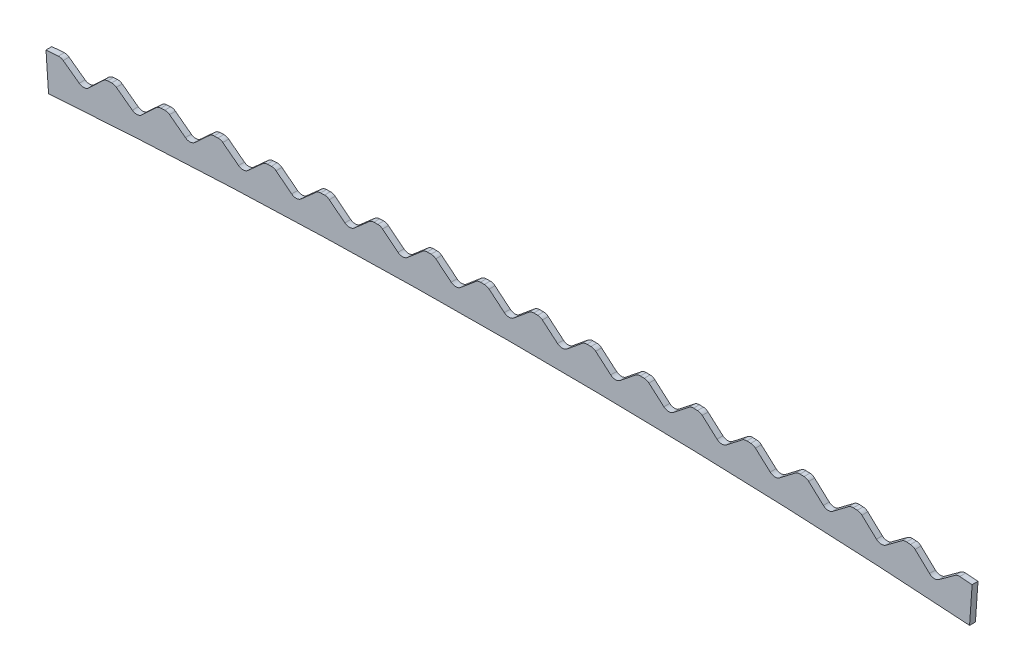
from build123d import *

# Parameters (mm, degrees)
BOSS_EXTRU_2_DEPTH                 = 8
ENL_V_MAT_EXTRU_1_DEPTH            = 9
CONG_1_R                           = 10
R_P_TITION_CIRCULAIRE1_COUNT       = 9
R_P_TITION_CIRCULAIRE1_ANGLE       = 3.68
CONG_1_OF_R_P_TITION_CIRCULAIRE1_R = 10
R_P_TITION_CIRCULAIRE2_COUNT       = 9
R_P_TITION_CIRCULAIRE2_ANGLE       = 3.68
CONG_1_OF_R_P_TITION_CIRCULAIRE2_R = 10


with BuildPart() as part:
    # Esquisse1 → Boss.-Extru.2 (new body)
    with BuildSketch(Plane.XY):
        with BuildLine():
            Line((627.808263697, -21.923547662), (631.296087384, 27.954654851))
            ThreePointArc((631.296087384, 27.954654851), (0, 50), (-631.296087384, 27.954654851))
            Line((-631.296087384, 27.954654851), (-627.808263697, -21.923547662))
            ThreePointArc((-627.808263697, -21.923547662), (0, 0), (627.808263697, -21.923547662))
        make_face()
    extrude(amount=BOSS_EXTRU_2_DEPTH)

    # Esquisse2 → Enlèv. mat.-Extru.1 (cut, through all)
    with BuildSketch(Plane.XY.offset(8)):
        Polygon((0, 25), (30, 49.950276106), (0, 74.995327729), (-30, 49.950276106), align=None)
    enl_v_mat_extru_1 = extrude(amount=-ENL_V_MAT_EXTRU_1_DEPTH, mode=Mode.SUBTRACT)

    # Congé1
    cong_1_edges = [part.edges().sort_by_distance(p)[0] for p in [
        (0, 25, 4),
        (-30, 49.950276106, 4),
        (30, 49.950276106, 4),
    ]]
    fillet(cong_1_edges, radius=CONG_1_R)

    # Répétition circulaire1: Enlèv. mat.-Extru.1 ×9 about axis
    r_p_tition_circulaire1_axis = Axis((0, -9000, 0), (0, 0, 1))
    for i in range(1, R_P_TITION_CIRCULAIRE1_COUNT):
        add(enl_v_mat_extru_1.rotate(r_p_tition_circulaire1_axis, i * R_P_TITION_CIRCULAIRE1_ANGLE / (R_P_TITION_CIRCULAIRE1_COUNT - 1)), mode=Mode.SUBTRACT)

    # Congé1 of Répétition circulaire1
    cong_1_of_r_p_tition_circulaire1_edges = [part.edges().sort_by_distance(p)[0] for p in [
        (-72.456565501, 24.709139142, 4),
        (-102.655910154, 49.417758293, 4),
        (-42.657843855, 49.899463992, 4),
        (-144.908460692, 23.836575317, 4),
        (-175.305203447, 48.301944876, 4),
        (-115.312938126, 49.265325224, 4),
        (-217.351015561, 22.382364766, 4),
        (-247.943197144, 46.602907776, 4),
        (-187.960599706, 48.047900678, 4),
        (-289.779560701, 20.346601223, 4),
        (-320.565209242, 44.320756509, 4),
        (-260.596145965, 46.247268824, 4),
        (-362.189427606, 17.729415908, 4),
        (-393.166558764, 41.455638174, 4),
        (-333.214895057, 43.863545726, 4),
        (-434.575948977, 14.530977515, 4),
        (-465.742566067, 38.007737447, 4),
        (-405.812166217, 40.89688503, 4),
        (-506.934459016, 10.751492204, 4),
        (-538.288553142, 33.977276569, 4),
        (-478.383280064, 37.347477958, 4),
        (-579.260293733, 6.39120359, 4),
        (-610.799843913, 29.364515329, 4),
        (-550.923558903, 33.215553293, 4),
    ]]
    fillet(cong_1_of_r_p_tition_circulaire1_edges, radius=CONG_1_OF_R_P_TITION_CIRCULAIRE1_R)

    # Répétition circulaire2: Enlèv. mat.-Extru.1 ×9 about axis
    r_p_tition_circulaire2_axis = Axis((0, -9000, 0), (0, 0, -1))
    for i in range(1, R_P_TITION_CIRCULAIRE2_COUNT):
        add(enl_v_mat_extru_1.rotate(r_p_tition_circulaire2_axis, i * R_P_TITION_CIRCULAIRE2_ANGLE / (R_P_TITION_CIRCULAIRE2_COUNT - 1)), mode=Mode.SUBTRACT)

    # Congé1 of Répétition circulaire2
    cong_1_of_r_p_tition_circulaire2_edges = [part.edges().sort_by_distance(p)[0] for p in [
        (72.456565501, 24.709139142, 4),
        (42.657843855, 49.899463992, 4),
        (102.655910154, 49.417758293, 4),
        (144.908460692, 23.836575317, 4),
        (115.312938126, 49.265325224, 4),
        (175.305203447, 48.301944876, 4),
        (217.351015561, 22.382364766, 4),
        (187.960599706, 48.047900678, 4),
        (247.943197144, 46.602907776, 4),
        (289.779560701, 20.346601223, 4),
        (260.596145965, 46.247268824, 4),
        (320.565209242, 44.320756509, 4),
        (362.189427606, 17.729415908, 4),
        (333.214895057, 43.863545726, 4),
        (393.166558764, 41.455638174, 4),
        (434.575948977, 14.530977515, 4),
        (405.812166217, 40.89688503, 4),
        (465.742566067, 38.007737447, 4),
        (506.934459016, 10.751492204, 4),
        (478.383280064, 37.347477958, 4),
        (538.288553142, 33.977276569, 4),
        (579.260293733, 6.39120359, 4),
        (550.923558903, 33.215553293, 4),
        (610.799843913, 29.364515329, 4),
    ]]
    fillet(cong_1_of_r_p_tition_circulaire2_edges, radius=CONG_1_OF_R_P_TITION_CIRCULAIRE2_R)


solid = part.part
